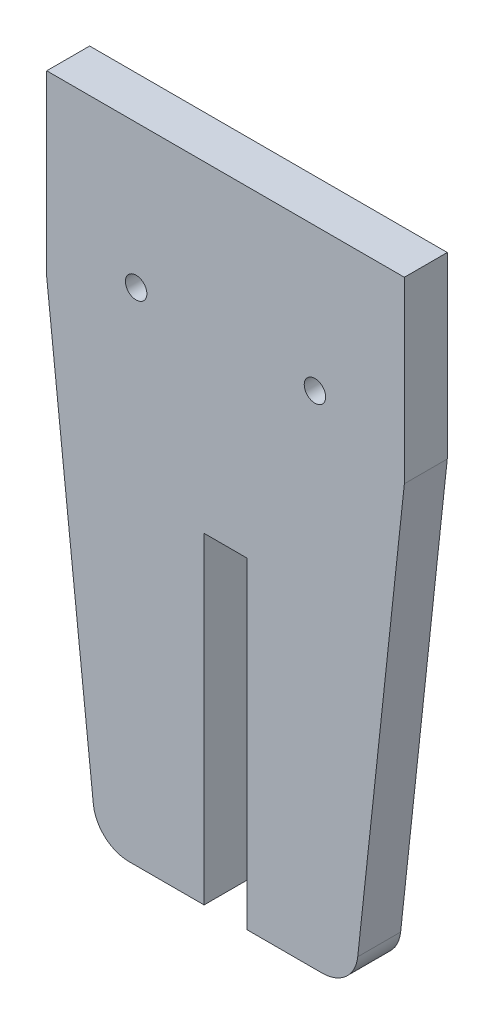
from build123d import *

# Parameters (mm, degrees)
BOSS_EXTRUDE1_DEPTH     = 6
SKETCH3_W               = 6
SKETCH3_H               = 45
CUT_EXTRUDE1_DEPTH      = 1
CUT_EXTRUDE1_DEPTH_BACK = 7
FILLET1_R               = 5
CUT_EXTRUDE2_START      = -7
SKETCH4_R               = 1.5
CUT_EXTRUDE2_DEPTH      = 8


with BuildPart() as part:
    # Sketch1 → Boss-Extrude1 (new body)
    with BuildSketch(Plane.XY):
        Polygon((25, 0), (-25, 0), (-25, -25), (-18, -90), (18, -90), (25, -25), align=None)
    extrude(amount=BOSS_EXTRUDE1_DEPTH)

    # Sketch3 → Cut-Extrude1 (cut, two sides)
    with BuildSketch(Plane.XY.offset(6)) as cut_extrude1_sk:
        with Locations((0, -67.5)):
            Rectangle(SKETCH3_W, SKETCH3_H)
    extrude(amount=CUT_EXTRUDE1_DEPTH, mode=Mode.SUBTRACT)
    extrude(cut_extrude1_sk.sketch, amount=-CUT_EXTRUDE1_DEPTH_BACK, mode=Mode.SUBTRACT)

    # Fillet1
    fillet1_edges = [part.edges().sort_by_distance(p)[0] for p in [
        (18, -90, 3),
        (-18, -90, 3),
    ]]
    fillet(fillet1_edges, radius=FILLET1_R)

    # Sketch4 → Cut-Extrude2 (cut)
    with BuildSketch(Plane(origin=(0, 0, 0), x_dir=(-1, 0, 0), z_dir=(0, 0, -1)).offset(CUT_EXTRUDE2_START)):
        with Locations((-12.5, -20)):
            Circle(SKETCH4_R)
    cut_extrude2 = extrude(amount=CUT_EXTRUDE2_DEPTH, mode=Mode.SUBTRACT)

    # Mirror1: Cut-Extrude2 across plane
    add(cut_extrude2.mirror(Plane(origin=(0, 0, 0), x_dir=(0, 0, 1), z_dir=(1, 0, 0))), mode=Mode.SUBTRACT)


solid = part.part
